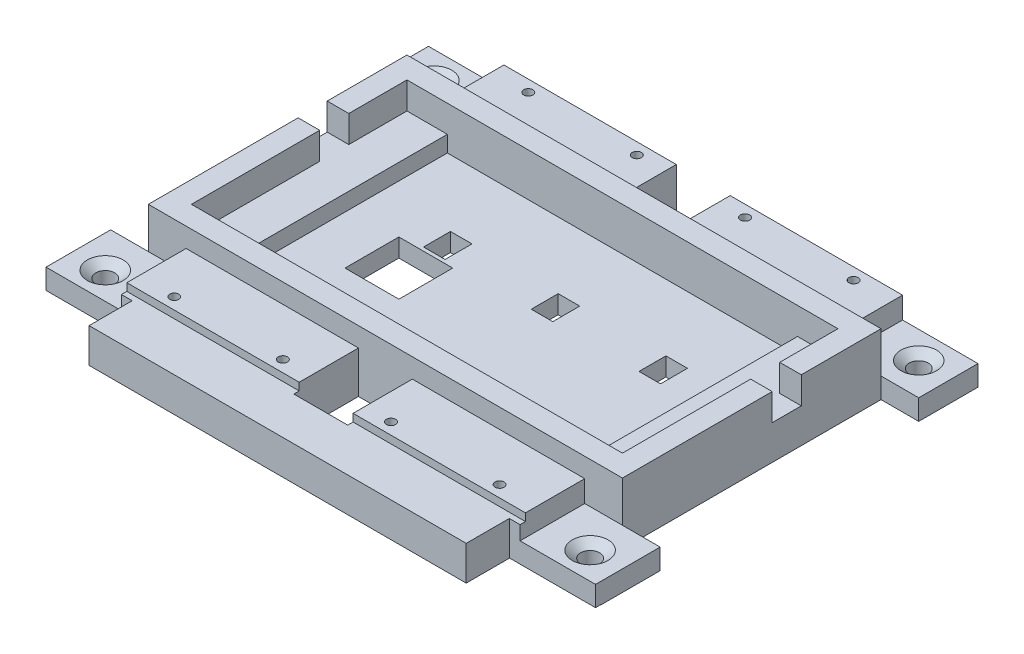
from build123d import *

# Parameters (mm, degrees)
SKETCH5_W                                         = 129.54
SKETCH5_H                                         = 88.9
BUTTON_SUPPORT_DEPTH                              = 48.768
SKETCH6_W                                         = 111.76
SKETCH6_H                                         = 60.96
SKETCH6_W_2                                       = 101.6
SKETCH6_H_2                                       = 50.8
BOSS_EXTRUDE4_DEPTH                               = 6.35
SKETCH7_W                                         = 82.55
SKETCH7_H                                         = 50.8
FORCE_SENSOR_CUTOUT_DEPTH                         = 3.81
SKETCH4_W                                         = 129.54
SKETCH4_H                                         = 40.64
BOTTOM_CUT_DEPTH                                  = 139.7
SKETCH25_W                                        = 111.76
SKETCH25_H                                        = 13.97
NEOPIXEL_LIFT_DEPTH                               = 1.778
SKETCH8_W                                         = 5.08
SKETCH8_H                                         = 6.35
HAPTIC_WIRE_HOLES_DEPTH                           = 4.318
SKETCH9_W                                         = 12.7
SKETCH9_H                                         = 12.7
FORCE_SENSOR_HOLE_DEPTH                           = 4.318
SKETCH10_R                                        = 1.0795
NEOPIXEL_HOLES_DEPTH                              = 9.906
NEOPIXEL_WIRE_SIDE_HOLES_REACH                    = 10.128
SKETCH18_W                                        = 8.89
SKETCH18_H                                        = 60.96
SKETCH19_W                                        = 12.7
SKETCH19_H                                        = 13.97
SKETCH19_W_2                                      = 17.78
NEOPIXEL_SOLDER_GAP_DEPTH                         = 5.08
BOSS_EXTRUDE6_DEPTH                               = 1.27
SKETCH11_W                                        = 88.9
SKETCH11_H                                        = 8.128
BOSS_EXTRUDE5_DEPTH                               = 10.16
CSK_FOR_8_FLAT_HEAD_MACHINE_SCREW_100_D           = 4.4958
CSK_FOR_8_FLAT_HEAD_MACHINE_SCREW_100_CSINK_D     = 8.4328
CSK_FOR_8_FLAT_HEAD_MACHINE_SCREW_100_CSINK_ANGLE = 100
SKETCH23_W                                        = 12.7
SKETCH23_H                                        = 13.97
SKETCH23_H_2                                      = 15.24
CUT_EXTRUDE1_DEPTH                                = 5.826
SKETCH24_W                                        = 6.858
SKETCH24_H                                        = 6.35
CUT_EXTRUDE2_DEPTH                                = 121.65


with BuildPart() as part:
    # Sketch5 → Button Support (new body)
    with BuildSketch(Plane(origin=(0, 5.08, 0), x_dir=(1, 0, 0), z_dir=(0, 1, 0))):
        with Locations((69.85, 60.96)):
            Rectangle(SKETCH5_W, SKETCH5_H)
    extrude(amount=BUTTON_SUPPORT_DEPTH)

    # Sketch6 → Boss-Extrude4 (add)
    with BuildSketch(Plane(origin=(0, 53.848, 0), x_dir=(1, 0, 0), z_dir=(0, 1, 0))):
        with Locations((69.85, 60.96)):
            Rectangle(SKETCH6_W, SKETCH6_H)
        with Locations((69.85, 60.96)):
            Rectangle(SKETCH6_W_2, SKETCH6_H_2, mode=Mode.SUBTRACT)
    extrude(amount=BOSS_EXTRUDE4_DEPTH)

    # Sketch7 → Force Sensor Cutout (cut)
    with BuildSketch(Plane(origin=(0, 53.848, 0), x_dir=(1, 0, 0), z_dir=(0, 1, 0))):
        with Locations((69.85, 60.96)):
            Rectangle(SKETCH7_W, SKETCH7_H)
    extrude(amount=-FORCE_SENSOR_CUTOUT_DEPTH, mode=Mode.SUBTRACT)

    # Sketch4 → Bottom Cut (cut)
    with BuildSketch(Plane.XY):
        with Locations((69.85, 25.4)):
            Rectangle(SKETCH4_W, SKETCH4_H)
    extrude(amount=-BOTTOM_CUT_DEPTH, mode=Mode.SUBTRACT)

    # Sketch25 → NeoPixel Lift (add)
    with BuildSketch(Plane(origin=(0, 53.848, 0), x_dir=(1, 0, 0), z_dir=(0, 1, 0))):
        with Locations((69.85, 98.425)):
            Rectangle(SKETCH25_W, SKETCH25_H)
        with Locations((69.85, 23.495)):
            Rectangle(SKETCH25_W, SKETCH25_H)
    extrude(amount=NEOPIXEL_LIFT_DEPTH)

    # Sketch8 → Haptic Wire Holes (cut)
    with BuildSketch(Plane(origin=(0, 50.038, 0), x_dir=(1, 0, 0), z_dir=(0, 1, 0))):
        with Locations((72.898, 67.528002358)):
            Rectangle(SKETCH8_W, SKETCH8_H)
        with Locations((98.298, 67.528002358)):
            Rectangle(SKETCH8_W, SKETCH8_H)
        with Locations((47.498, 67.528002358)):
            Rectangle(SKETCH8_W, SKETCH8_H)
    extrude(amount=-HAPTIC_WIRE_HOLES_DEPTH, mode=Mode.SUBTRACT)

    # Sketch9 → Force Sensor Hole (cut)
    with BuildSketch(Plane(origin=(0, 50.038, 0), x_dir=(1, 0, 0), z_dir=(0, 1, 0))):
        with Locations((46.355, 57.15)):
            Rectangle(SKETCH9_W, SKETCH9_H)
    extrude(amount=-FORCE_SENSOR_HOLE_DEPTH, mode=Mode.SUBTRACT)

    # Sketch10 → NeoPixel Holes (cut)
    with BuildSketch(Plane(origin=(0, 55.626, 0), x_dir=(1, 0, 0), z_dir=(0, 1, 0))):
        with Locations((108.018583302, 19.2294764)):
            Circle(SKETCH10_R)
        with Locations((82.42609372, 19.2294764)):
            Circle(SKETCH10_R)
        with Locations((56.918583394, 19.2294764)):
            Circle(SKETCH10_R)
        with Locations((31.326093812, 19.2294764)):
            Circle(SKETCH10_R)
        with Locations((31.326093812, 102.6905236)):
            Circle(SKETCH10_R)
        with Locations((56.918583394, 102.6905236)):
            Circle(SKETCH10_R)
        with Locations((82.42609372, 102.6905236)):
            Circle(SKETCH10_R)
        with Locations((108.018583302, 102.6905236)):
            Circle(SKETCH10_R)
    extrude(amount=-NEOPIXEL_HOLES_DEPTH, mode=Mode.SUBTRACT)

    # Sketch18 → Neopixel Wire Side Holes (cut, up to next)
    with BuildSketch(Plane(origin=(0, 53.848, 0), x_dir=(1, 0, 0), z_dir=(0, 1, 0)), mode=Mode.PRIVATE) as neopixel_wire_side_holes_sk1:
        with Locations((130.175, 60.96)):
            Rectangle(SKETCH18_W, SKETCH18_H)
    neopixel_wire_side_holes_tool1 = extrude(neopixel_wire_side_holes_sk1.sketch, amount=-NEOPIXEL_WIRE_SIDE_HOLES_REACH, mode=Mode.PRIVATE) & part.part
    add(neopixel_wire_side_holes_tool1.solids().sort_by_distance((130.175, 53.848, -60.96))[0], mode=Mode.SUBTRACT)
    # Sketch18 → Neopixel Wire Side Holes (cut, up to next)
    with BuildSketch(Plane(origin=(0, 53.848, 0), x_dir=(1, 0, 0), z_dir=(0, 1, 0)), mode=Mode.PRIVATE) as neopixel_wire_side_holes_sk2:
        with Locations((9.525, 60.96)):
            Rectangle(SKETCH18_W, SKETCH18_H)
    neopixel_wire_side_holes_tool2 = extrude(neopixel_wire_side_holes_sk2.sketch, amount=-NEOPIXEL_WIRE_SIDE_HOLES_REACH, mode=Mode.PRIVATE) & part.part
    add(neopixel_wire_side_holes_tool2.solids().sort_by_distance((9.525, 53.848, -60.96))[0], mode=Mode.SUBTRACT)

    # Sketch19 → NeoPixel solder gap (cut)
    with BuildSketch(Plane(origin=(0, 55.626, 0), x_dir=(1, 0, 0), z_dir=(0, 1, 0))):
        with Locations((69.85, 98.425)):
            Rectangle(SKETCH19_W, SKETCH19_H)
        with Locations((13.97, 98.425)):
            Rectangle(SKETCH19_W_2, SKETCH19_H)
        with Locations((125.73, 98.425)):
            Rectangle(SKETCH19_W_2, SKETCH19_H)
    neopixel_solder_gap = extrude(amount=-NEOPIXEL_SOLDER_GAP_DEPTH, mode=Mode.SUBTRACT)

    # Mirror1: NeoPixel solder gap across plane
    add(neopixel_solder_gap.mirror(Plane.XY.offset(-60.96)), mode=Mode.SUBTRACT)

    # Sketch20 → Boss-Extrude6 (add)
    with BuildSketch(Plane.XY.offset(-16.51)):
        Polygon((22.86, 50.546), (5.08, 50.546), (5.08, 45.786808958), (134.62, 45.786808958), (134.62, 50.546), (116.84, 50.546), (116.84, 53.848), (76.2, 53.848), (76.2, 50.546), (63.5, 50.546), (63.5, 53.848), (22.86, 53.848), align=None)
    extrude(amount=BOSS_EXTRUDE6_DEPTH)

    # Sketch11 → Boss-Extrude5 (add)
    with BuildSketch(Plane.XY.offset(-15.24)):
        with Locations((69.85, 49.784)):
            Rectangle(SKETCH11_W, SKETCH11_H)
    extrude(amount=BOSS_EXTRUDE5_DEPTH)

    # CSK for #8 Flat Head Machine Screw (100)1 (through all)
    with Locations(Plane(origin=(0, 50.546, 0), x_dir=(1, 0, 0), z_dir=(0, 1, 0))):
        with Locations((12.7, 99.06), (127, 99.06), (127, 21.59), (12.7, 21.59)):
            CounterSinkHole(CSK_FOR_8_FLAT_HEAD_MACHINE_SCREW_100_D / 2, CSK_FOR_8_FLAT_HEAD_MACHINE_SCREW_100_CSINK_D / 2, counter_sink_angle=CSK_FOR_8_FLAT_HEAD_MACHINE_SCREW_100_CSINK_ANGLE)

    # Sketch23 → Cut-Extrude1 (cut, through all)
    with BuildSketch(Plane(origin=(0, 50.546, 0), x_dir=(1, 0, 0), z_dir=(0, 1, 0))):
        with Locations((69.85, 98.425)):
            Rectangle(SKETCH23_W, SKETCH23_H)
        with Locations((69.85, 22.86)):
            Rectangle(SKETCH23_W, SKETCH23_H_2)
    extrude(amount=-CUT_EXTRUDE1_DEPTH, mode=Mode.SUBTRACT)

    # Sketch24 → Cut-Extrude2 (cut, through all)
    with BuildSketch(Plane(origin=(125.73, 0, 0), x_dir=(0, 0, -1), z_dir=(1, 0, 0))):
        with Locations((69.215, 57.023)):
            Rectangle(SKETCH24_W, SKETCH24_H)
    extrude(amount=-CUT_EXTRUDE2_DEPTH, mode=Mode.SUBTRACT)


solid = part.part
